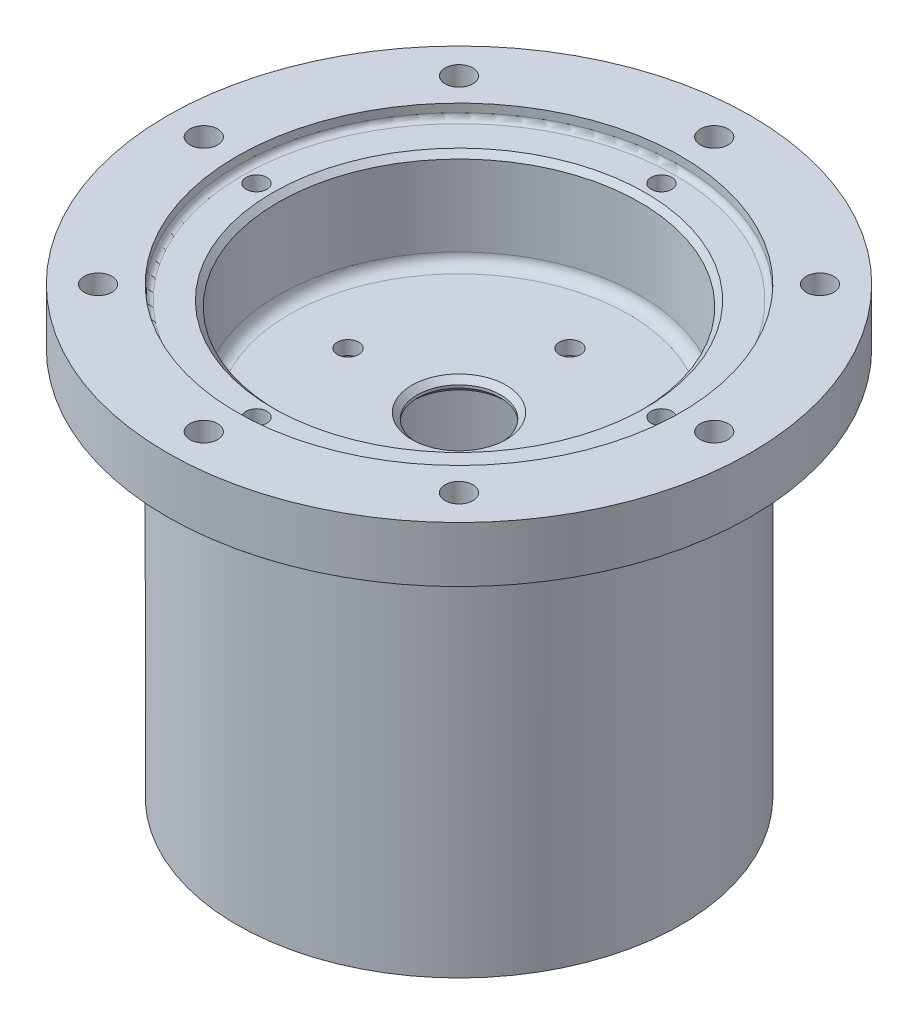
from build123d import *

# Parameters (mm, degrees)
F_10_0_1935_DIAMETER_HOLE1_D       = 4.9149
F_3_16_0_1875_DIAMETER_HOLE1_D     = 4.7625
F_3_16_0_1875_DIAMETER_HOLE1_DEPTH = 6.35
F_3_16_0_1875_DIAMETER_HOLE1_TIP   = 1.430799349
FILLET1_R                          = 2.54
FILLET2_R                          = 1.27
CHAMFER1_SIZE                      = 1.27
F_1_4_0_25_DIAMETER_HOLE2_D        = 6.35
F_1_4_0_25_DIAMETER_HOLE2_DEPTH    = 12.7
F_1_4_0_25_DIAMETER_HOLE2_TIP      = 1.907732465


with BuildPart() as part:
    # Sketch1 → Revolve1 (revolve)
    with BuildSketch(Plane.XY):
        Polygon((-66.802, 50.8), (-66.802, 38.1), (-50.8, 38.1), (-50.8, -50.8), (-41.402, -50.8), (-41.402, 22.225), (-9.525, 22.225), (-9.525, 25.4), (-41.402, 25.4), (-41.402, 47.625), (-50.8, 47.625), (-50.8, 50.8), align=None)
    revolve(axis=Axis((0, 50.8, 0), (0, -1, 0)))

    # #10 (0.1935) Diameter Hole1 (through all)
    with Locations(Plane(origin=(0, 25.4, 0), x_dir=(1, 0, 0), z_dir=(0, 1, 0))):
        with Locations((0, 25.4), (25.4, 0), (0, -25.4), (-25.4, 0)):
            Hole(F_10_0_1935_DIAMETER_HOLE1_D / 2)

    # 3/16 (0.1875) Diameter Hole1
    with Locations(Plane(origin=(0, 47.625, 0), x_dir=(1, 0, 0), z_dir=(0, 1, 0))):
        with Locations((0, 46.355), (46.355, 0), (0, -46.355), (-46.355, 0)):
            Hole(F_3_16_0_1875_DIAMETER_HOLE1_D / 2, depth=F_3_16_0_1875_DIAMETER_HOLE1_DEPTH)
            with Locations((0, 0, -(F_3_16_0_1875_DIAMETER_HOLE1_DEPTH + F_3_16_0_1875_DIAMETER_HOLE1_TIP / 2))):  # 118° drill point
                Cone(0, F_3_16_0_1875_DIAMETER_HOLE1_D / 2, F_3_16_0_1875_DIAMETER_HOLE1_TIP, mode=Mode.SUBTRACT)

    # Fillet1
    fillet1_edges = [part.edges().sort_by_distance(p)[0] for p in [
        (41.402, 22.225, 0),
        (41.402, 25.4, 0),
        (50.8, 38.1, 0),
    ]]
    fillet(fillet1_edges, radius=FILLET1_R)

    # Fillet2
    fillet2_edges = [part.edges().sort_by_distance(p)[0] for p in [
        (50.8, 47.625, 0),
    ]]
    fillet(fillet2_edges, radius=FILLET2_R)

    # Chamfer1
    chamfer1_edges = [part.edges().sort_by_distance(p)[0] for p in [
        (9.525, 22.225, 0),
        (9.525, 25.4, 0),
        (41.402, 47.625, 0),
    ]]
    chamfer(chamfer1_edges, length=CHAMFER1_SIZE)

    # 1/4 (0.25) Diameter Hole2
    with Locations(Plane(origin=(0, 50.8, 0), x_dir=(1, 0, 0), z_dir=(0, 1, 0))):
        with Locations((0, 58.42), (41.309178157, 41.309178157), (58.42, 0), (41.309178157, -41.309178157), (0, -58.42), (-41.309178157, -41.309178157), (-58.42, 0), (-41.309178157, 41.309178157), (0, 0)):
            Hole(F_1_4_0_25_DIAMETER_HOLE2_D / 2, depth=F_1_4_0_25_DIAMETER_HOLE2_DEPTH)
            with Locations((0, 0, -(F_1_4_0_25_DIAMETER_HOLE2_DEPTH + F_1_4_0_25_DIAMETER_HOLE2_TIP / 2))):  # 118° drill point
                Cone(0, F_1_4_0_25_DIAMETER_HOLE2_D / 2, F_1_4_0_25_DIAMETER_HOLE2_TIP, mode=Mode.SUBTRACT)


solid = part.part
